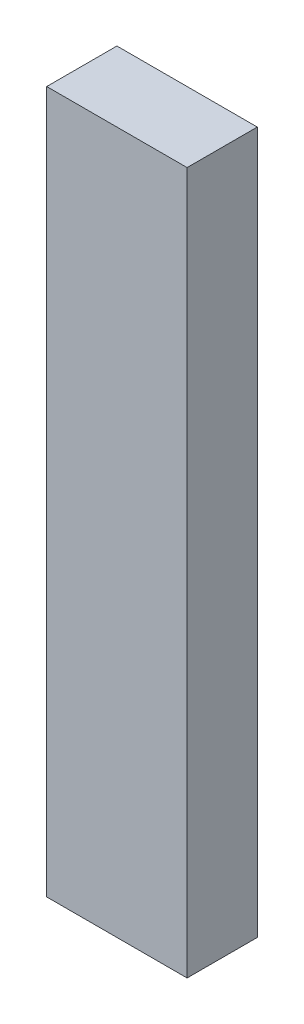
from build123d import *

# Parameters (mm, degrees)
SKETCH1_W           = 4
SKETCH1_H           = 20
BOSS_EXTRUDE1_DEPTH = 2


with BuildPart() as part:
    # Sketch1 → Boss-Extrude1 (new body)
    with BuildSketch(Plane.XY):
        with Locations((2, 10)):
            Rectangle(SKETCH1_W, SKETCH1_H)
    extrude(amount=BOSS_EXTRUDE1_DEPTH)


solid = part.part
